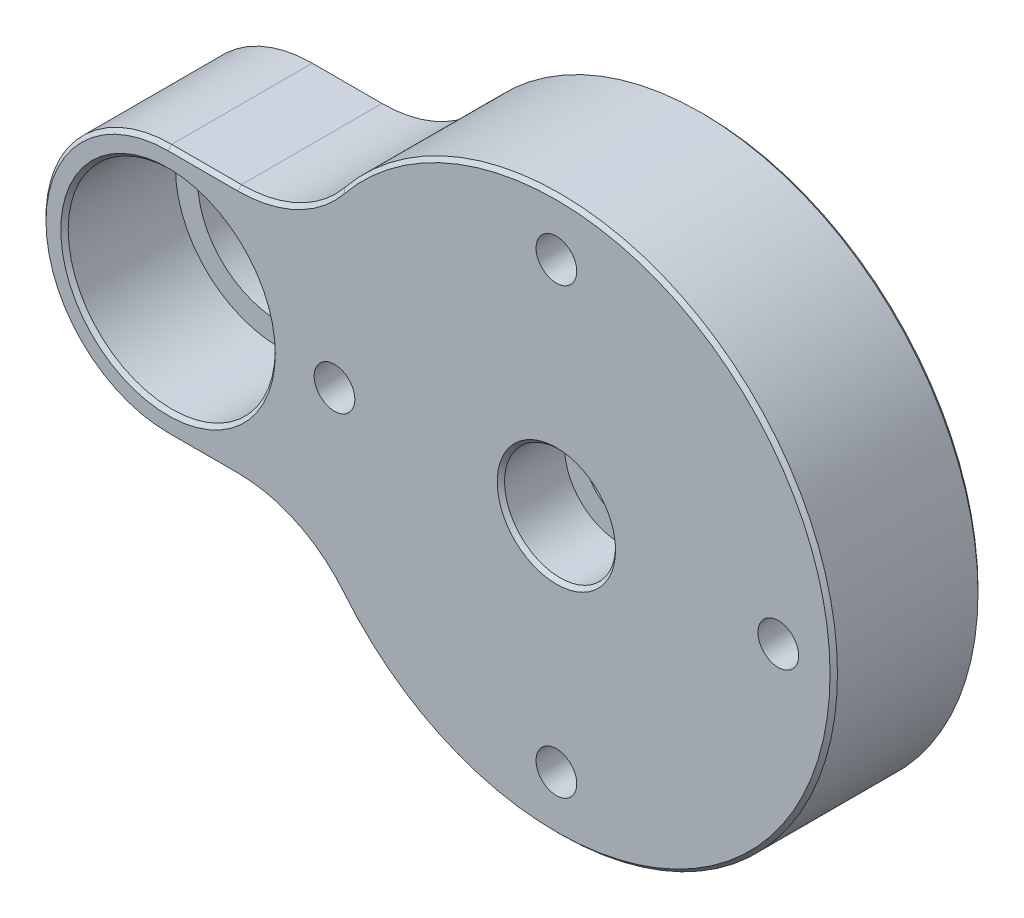
from build123d import *

# Parameters (mm, degrees)
BOSS_EXTRUDE1_DEPTH                                 = 20
SKETCH1_3_W                                         = 45
SKETCH1_3_H                                         = 45
CUT_EXTRUDE2_DEPTH                                  = 5
CBORE_FOR_M8_HEX_SOCKET_HEAD_CAP_SCREW1_D           = 9
CBORE_FOR_M8_HEX_SOCKET_HEAD_CAP_SCREW1_DEPTH       = 23
CBORE_FOR_M8_HEX_SOCKET_HEAD_CAP_SCREW1_CBORE_D     = 15
CBORE_FOR_M8_HEX_SOCKET_HEAD_CAP_SCREW1_CBORE_DEPTH = 8.6
CBORE_FOR_M8_HEX_SOCKET_HEAD_CAP_SCREW1_TIP         = 2.703872786
FILLET2_R                                           = 2.5
SKETCH4_R                                           = 11
CUT_EXTRUDE3_DEPTH                                  = 6
CUT_EXTRUDE4_DEPTH                                  = 1
CUT_EXTRUDE4_DEPTH_BACK                             = 81.202867779
SKETCH5_R                                           = 14
CHAMFER1_SIZE                                       = 0.5
CBORE_FOR_M5_HEX_SOCKET_HEAD_CAP_SCREW1_D           = 5.5
CBORE_FOR_M5_HEX_SOCKET_HEAD_CAP_SCREW1_CBORE_D     = 10
CBORE_FOR_M5_HEX_SOCKET_HEAD_CAP_SCREW1_CBORE_DEPTH = 5.4


with BuildPart() as part:
    # Sketch1 → Boss-Extrude1 (new body)
    with BuildSketch(Plane.XY):
        with BuildLine():
            Line((-43.072613109, 17), (-52.5, 17))
            ThreePointArc((-52.5, 17), (-69.5, 0), (-52.5, -17))
            Line((-52.5, -17), (-43.072613109, -17))
            ThreePointArc((-43.072613109, -17), (-35.337121021, -18.746933761), (-29.103116965, -23.648648649))
            ThreePointArc((-29.103116965, -23.648648649), (37.5, 0), (-29.103116965, 23.648648649))
            ThreePointArc((-29.103116965, 23.648648649), (-35.337121021, 18.746933761), (-43.072613109, 17))
        make_face()
    extrude(amount=BOSS_EXTRUDE1_DEPTH)

    # Sketch1_3 → Cut-Extrude2 (cut)
    with BuildSketch(Plane.XY):
        Rectangle(SKETCH1_3_W, SKETCH1_3_H)
    extrude(amount=CUT_EXTRUDE2_DEPTH, mode=Mode.SUBTRACT)

    # CBORE for M8 Hex Socket Head Cap Screw1
    with Locations(Plane.XY.offset(20)):
        with Locations((0, 0)):
            CounterBoreHole(CBORE_FOR_M8_HEX_SOCKET_HEAD_CAP_SCREW1_D / 2, CBORE_FOR_M8_HEX_SOCKET_HEAD_CAP_SCREW1_CBORE_D / 2, CBORE_FOR_M8_HEX_SOCKET_HEAD_CAP_SCREW1_CBORE_DEPTH, depth=CBORE_FOR_M8_HEX_SOCKET_HEAD_CAP_SCREW1_DEPTH)
            with Locations((0, 0, -(CBORE_FOR_M8_HEX_SOCKET_HEAD_CAP_SCREW1_DEPTH + CBORE_FOR_M8_HEX_SOCKET_HEAD_CAP_SCREW1_TIP / 2))):  # 118° drill point
                Cone(0, CBORE_FOR_M8_HEX_SOCKET_HEAD_CAP_SCREW1_D / 2, CBORE_FOR_M8_HEX_SOCKET_HEAD_CAP_SCREW1_TIP, mode=Mode.SUBTRACT)

    # Fillet2
    fillet2_edges = [part.edges().sort_by_distance(p)[0] for p in [
        (22.5, 22.5, 2.5),
        (22.5, -22.5, 2.5),
        (-22.5, -22.5, 2.5),
        (-22.5, 22.5, 2.5),
    ]]
    fillet(fillet2_edges, radius=FILLET2_R)

    # Sketch4 → Cut-Extrude3 (cut)
    with BuildSketch(Plane(origin=(0, 0, 0), x_dir=(-1, 0, 0), z_dir=(0, 0, -1))):
        with Locations((52.5, 0)):
            Circle(SKETCH4_R)
    extrude(amount=-CUT_EXTRUDE3_DEPTH, mode=Mode.SUBTRACT)

    # Sketch5 → Cut-Extrude4 (cut, two sides: drawn at the far end of the back side and taken through both)
    with BuildSketch(Plane(origin=(0, 0, 6), x_dir=(-1, 0, 0), z_dir=(0, 0, -1)).offset(-CUT_EXTRUDE4_DEPTH_BACK)):
        with Locations((52.5, 0)):
            Circle(SKETCH5_R)
    extrude(amount=CUT_EXTRUDE4_DEPTH + CUT_EXTRUDE4_DEPTH_BACK, mode=Mode.SUBTRACT)

    # Chamfer1
    chamfer1_edges = [part.edges().sort_by_distance(p)[0] for p in [
        (-38.5, 0, 20),
        (-7.5, 0, 20),
        (-35.337121021, 18.746933761, 20),
        (-41.5, 0, 0),
        (22.5, 0, 0),
        (21.767766953, -21.767766953, 0),
        (21.767766953, 21.767766953, 0),
        (0, -22.5, 0),
        (0, 22.5, 0),
        (-21.767766953, -21.767766953, 0),
        (-21.767766953, 21.767766953, 0),
        (-22.5, 0, 0),
        (-35.337121021, 18.746933761, 0),
        (-47.786306554, 17, 0),
        (-69.5, 0, 0),
        (37.5, 0, 0),
        (-47.786306554, -17, 0),
        (-35.337121021, -18.746933761, 0),
        (-47.786306554, 17, 20),
        (-69.5, 0, 20),
        (37.5, 0, 20),
        (-47.786306554, -17, 20),
        (-35.337121021, -18.746933761, 20),
    ]]
    chamfer(chamfer1_edges, length=CHAMFER1_SIZE)

    # CBORE for M5 Hex Socket Head Cap Screw1 (through all)
    with Locations(Plane(origin=(0, 0, 0), x_dir=(-1, 0, 0), z_dir=(0, 0, -1))):
        with Locations((0, 30), (-30, 0), (0, -30), (30, 0)):
            CounterBoreHole(CBORE_FOR_M5_HEX_SOCKET_HEAD_CAP_SCREW1_D / 2, CBORE_FOR_M5_HEX_SOCKET_HEAD_CAP_SCREW1_CBORE_D / 2, CBORE_FOR_M5_HEX_SOCKET_HEAD_CAP_SCREW1_CBORE_DEPTH)


solid = part.part
